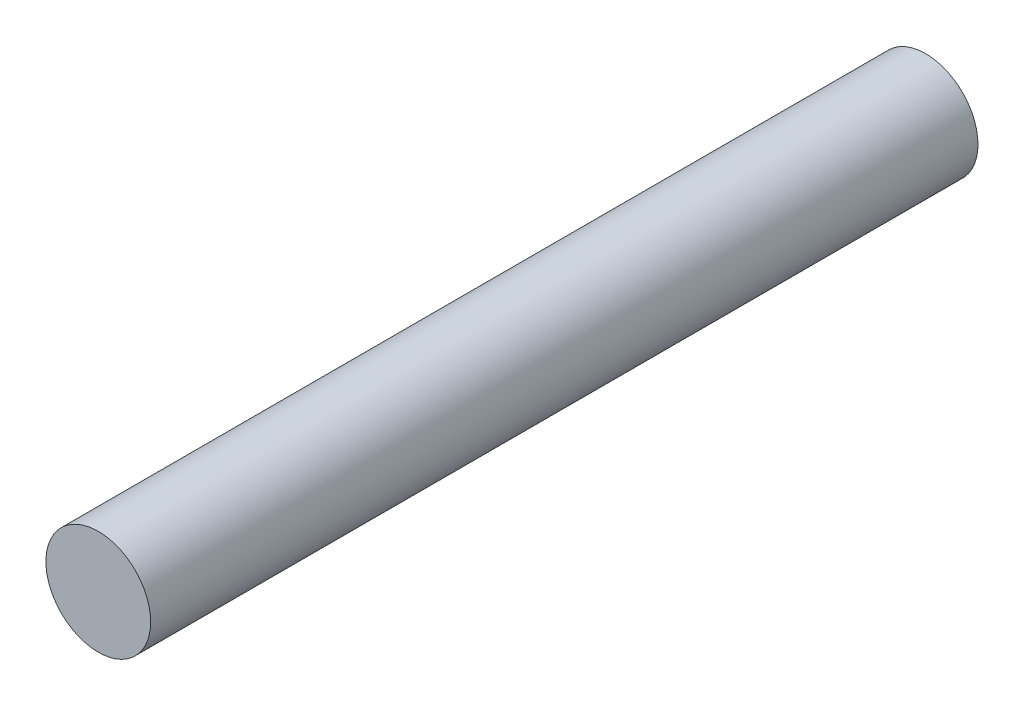
from build123d import *

# Parameters (mm, degrees)
SKETCH1_R           = 1
BOSS_EXTRUDE1_DEPTH = 7.9


with BuildPart() as part:
    # Sketch1 → Boss-Extrude1 (new body, symmetric)
    with BuildSketch(Plane.XY):
        Circle(SKETCH1_R)
    extrude(amount=BOSS_EXTRUDE1_DEPTH, both=True)


solid = part.part
